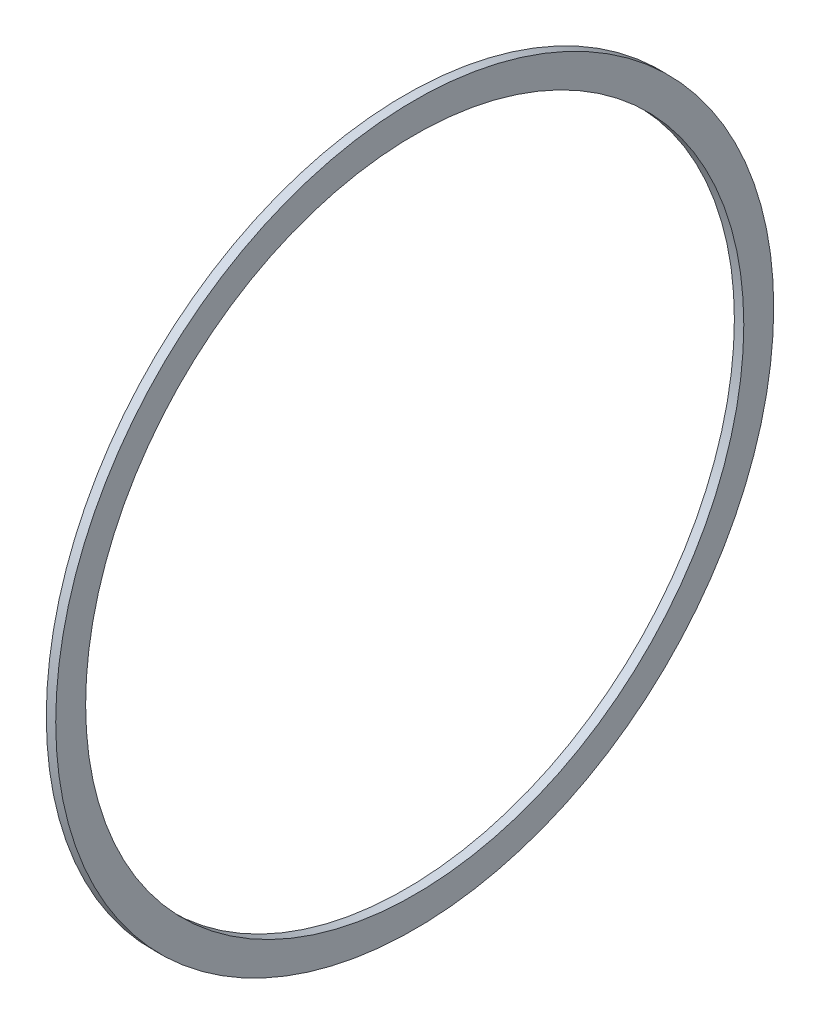
from build123d import *

# Parameters (mm, degrees)
SKETCH1_R           = 76.2
SKETCH1_R_2         = 69.85
BOSS_EXTRUDE1_DEPTH = 1


with BuildPart() as part:
    # Sketch1 → Boss-Extrude1 (new body, symmetric)
    with BuildSketch(Plane(origin=(0, 0, 0), x_dir=(0, 0, -1), z_dir=(1, 0, 0))):
        Circle(SKETCH1_R)
        Circle(SKETCH1_R_2, mode=Mode.SUBTRACT)
    extrude(amount=BOSS_EXTRUDE1_DEPTH, both=True)


solid = part.part
